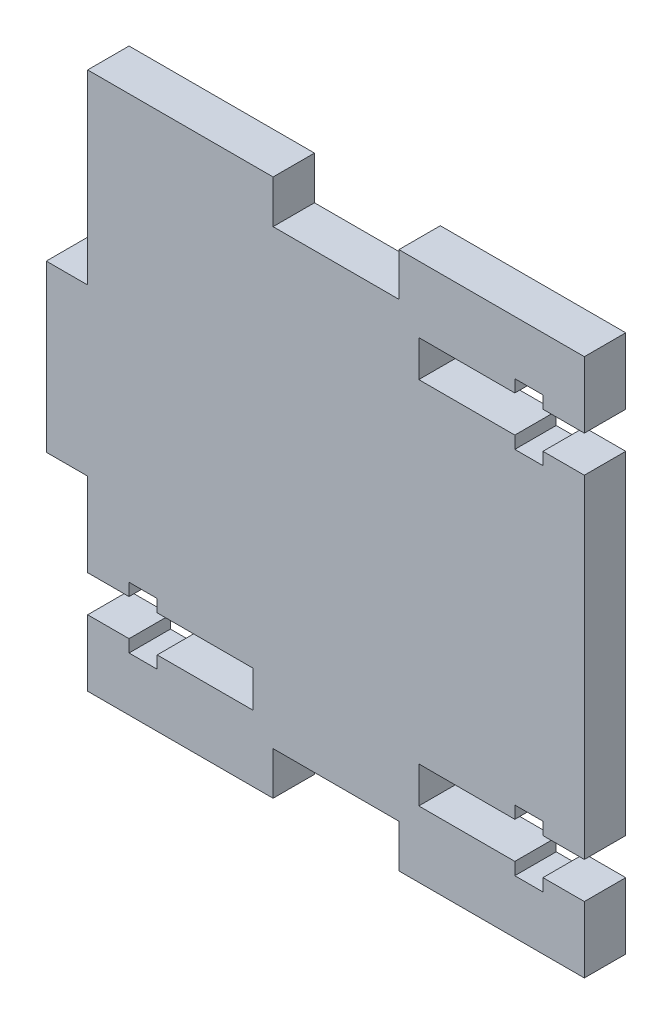
from build123d import *

# Parameters (mm, degrees)
BOSS_EXTRUDE1_DEPTH = 5
CUT_EXTRUDE1_DEPTH  = 5
SKETCH4_W           = 15.2
SKETCH4_H           = 5.2
CUT_EXTRUDE2_DEPTH  = 10


with BuildPart() as part:
    # Sketch1 → Boss-Extrude1 (new body)
    with BuildSketch(Plane.XY):
        Polygon((-30, 32.5), (-7.5, 32.5), (30, 32.5), (30, -32.5), (-30, -32.5), (-30, -10), (-35, -10), (-35, 10), (-30, 10), align=None)
    extrude(amount=BOSS_EXTRUDE1_DEPTH)

    # Sketch3 → Cut-Extrude1 (cut)
    with BuildSketch(Plane.XY.offset(5)):
        Polygon((30, 24.5), (25, 24.5), (25, 26), (21.6, 26), (21.6, 24.5), (10, 24.5), (10, 20.1), (21.6, 20.1), (21.6, 18.6), (25, 18.6), (25, 20.1), (30, 20.1), align=None)
        Polygon((30, -24.5), (30, -20.1), (25, -20.1), (25, -18.6), (21.6, -18.6), (21.6, -20.1), (10, -20.1), (10, -24.5), (21.6, -24.5), (21.6, -26), (25, -26), (25, -24.5), align=None)
        Polygon((-30, -24.5), (-25, -24.5), (-25, -26), (-21.6, -26), (-21.6, -24.5), (-10, -24.5), (-10, -20.1), (-21.6, -20.1), (-21.6, -18.6), (-25, -18.6), (-25, -20.1), (-30, -20.1), align=None)
    extrude(amount=-CUT_EXTRUDE1_DEPTH, mode=Mode.SUBTRACT)

    # Sketch4 → Cut-Extrude2 (cut)
    with BuildSketch(Plane.XY.offset(5)):
        with Locations((0, -29.9)):
            Rectangle(SKETCH4_W, SKETCH4_H)
        with Locations((0, 29.9)):
            Rectangle(SKETCH4_W, SKETCH4_H)
    extrude(amount=-CUT_EXTRUDE2_DEPTH, mode=Mode.SUBTRACT)


solid = part.part
